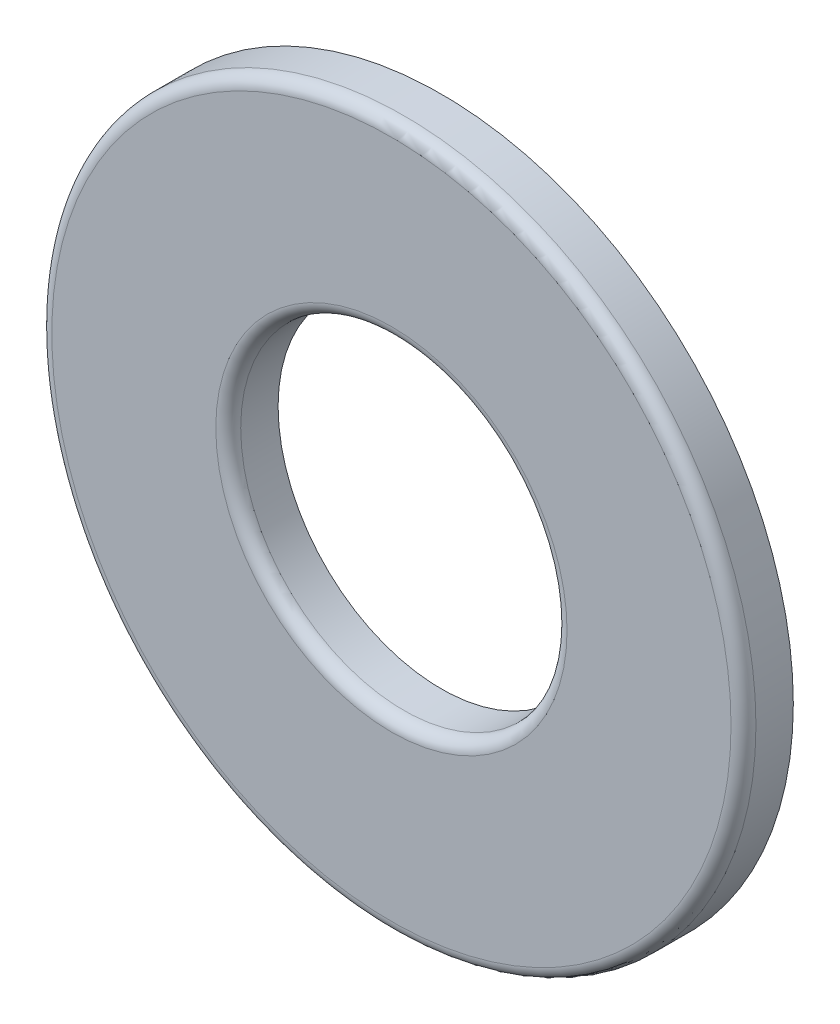
from build123d import *

# Parameters (mm, degrees)
SKETCH3_R                = 5.5626
SKETCH3_R_2              = 2.5781
BOSS_EXTRUDE1_DEPTH      = 0.3937
BOSS_EXTRUDE1_DEPTH_BACK = 0.3937
FILLET1_R                = 0.19685


with BuildPart() as part:
    # Sketch3 → Boss-Extrude1 (new body, two sides)
    with BuildSketch(Plane.XY) as boss_extrude1_sk:
        Circle(SKETCH3_R)
        Circle(SKETCH3_R_2, mode=Mode.SUBTRACT)
    extrude(amount=BOSS_EXTRUDE1_DEPTH)
    extrude(boss_extrude1_sk.sketch, amount=-BOSS_EXTRUDE1_DEPTH_BACK)

    # Fillet1
    fillet1_edges = [part.edges().sort_by_distance(p)[0] for p in [
        (-5.5626, 0, 0.3937),
        (-2.5781, 0, 0.3937),
    ]]
    fillet(fillet1_edges, radius=FILLET1_R)


solid = part.part
